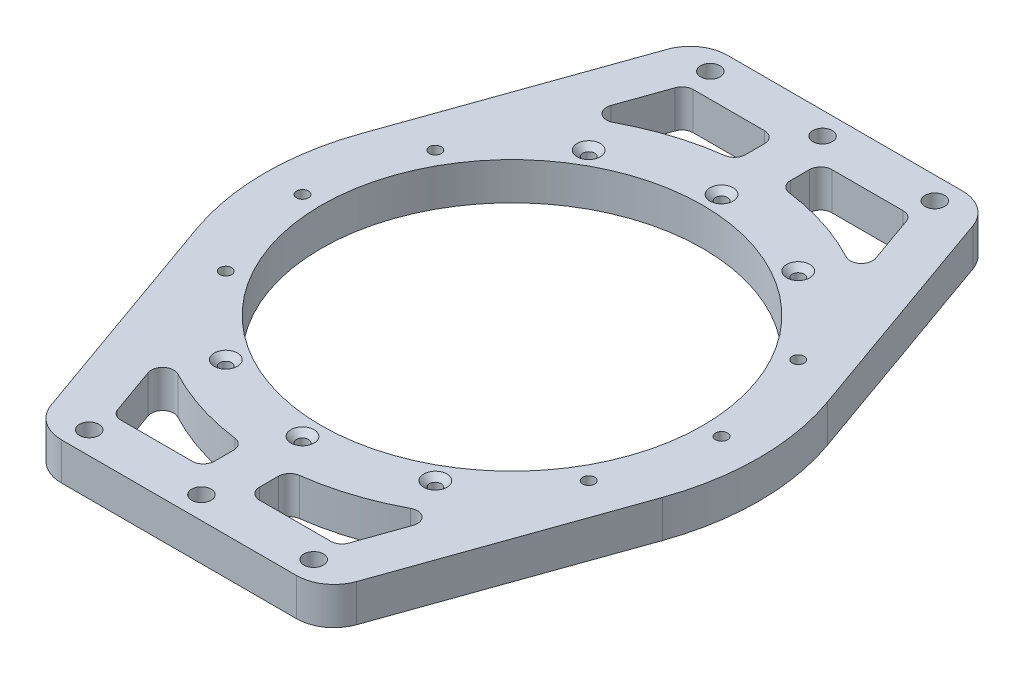
from build123d import *

# Parameters (mm, degrees)
SKETCH_1_W          = 240
SKETCH_1_H          = 180
SKETCH_1_R          = 51
SKETCH_1_R_2        = 1.6
SKETCH_1_R_3        = 2.1
SKETCH_1_R_4        = 1.25
EXTRUDE_1_DEPTH     = 10
CUT_EXTRUDE_1_DEPTH = 11
SKETCH_3_R          = 2.6
SKETCH_3_W          = 240
SKETCH_3_H          = 1
CUT_EXTRUDE_2_DEPTH = 11
CUT_EXTRUDE_3_DEPTH = 11
FILLET_1_R          = 10
CUT_EXTRUDE_4_DEPTH = 11
CHAMFER_1_SIZE      = 1.5


with BuildPart() as part:
    # 草图1 → 凸台-拉伸1 (new body)
    with BuildSketch(Plane(origin=(0, 0, 0), x_dir=(1, 0, 0), z_dir=(0, 1, 0))):
        Rectangle(SKETCH_1_W, SKETCH_1_H)
        Circle(SKETCH_1_R, mode=Mode.SUBTRACT)
        with Locations((0, 56)):
            Circle(SKETCH_1_R_2, mode=Mode.SUBTRACT)
        with Locations((28, 48.497422612)):
            Circle(SKETCH_1_R_2, mode=Mode.SUBTRACT)
        with Locations((48.497422612, 28)):
            Circle(SKETCH_1_R_2, mode=Mode.SUBTRACT)
        with Locations((56, 0)):
            Circle(SKETCH_1_R_2, mode=Mode.SUBTRACT)
        with Locations((48.497422612, -28)):
            Circle(SKETCH_1_R_2, mode=Mode.SUBTRACT)
        with Locations((28, -48.497422612)):
            Circle(SKETCH_1_R_2, mode=Mode.SUBTRACT)
        with Locations((0, -56)):
            Circle(SKETCH_1_R_2, mode=Mode.SUBTRACT)
        with Locations((-28, -48.497422612)):
            Circle(SKETCH_1_R_2, mode=Mode.SUBTRACT)
        with Locations((-48.497422612, -28)):
            Circle(SKETCH_1_R_2, mode=Mode.SUBTRACT)
        with Locations((-56, 0)):
            Circle(SKETCH_1_R_2, mode=Mode.SUBTRACT)
        with Locations((-48.497422612, 28)):
            Circle(SKETCH_1_R_2, mode=Mode.SUBTRACT)
        with Locations((-28, 48.497422612)):
            Circle(SKETCH_1_R_2, mode=Mode.SUBTRACT)
        with Locations((-70, 85)):
            Circle(SKETCH_1_R_3, mode=Mode.SUBTRACT)
        with Locations((-50, 85)):
            Circle(SKETCH_1_R_3, mode=Mode.SUBTRACT)
        with Locations((-70, 65)):
            Circle(SKETCH_1_R_3, mode=Mode.SUBTRACT)
        with Locations((-50, 65)):
            Circle(SKETCH_1_R_3, mode=Mode.SUBTRACT)
        with Locations((50, 85)):
            Circle(SKETCH_1_R_3, mode=Mode.SUBTRACT)
        with Locations((50, 65)):
            Circle(SKETCH_1_R_3, mode=Mode.SUBTRACT)
        with Locations((70, 65)):
            Circle(SKETCH_1_R_3, mode=Mode.SUBTRACT)
        with Locations((70, 85)):
            Circle(SKETCH_1_R_3, mode=Mode.SUBTRACT)
        with Locations((70, -85)):
            Circle(SKETCH_1_R_3, mode=Mode.SUBTRACT)
        with Locations((70, -65)):
            Circle(SKETCH_1_R_3, mode=Mode.SUBTRACT)
        with Locations((50, -65)):
            Circle(SKETCH_1_R_3, mode=Mode.SUBTRACT)
        with Locations((50, -85)):
            Circle(SKETCH_1_R_3, mode=Mode.SUBTRACT)
        with Locations((-50, -65)):
            Circle(SKETCH_1_R_3, mode=Mode.SUBTRACT)
        with Locations((-70, -65)):
            Circle(SKETCH_1_R_3, mode=Mode.SUBTRACT)
        with Locations((-50, -85)):
            Circle(SKETCH_1_R_3, mode=Mode.SUBTRACT)
        with Locations((-70, -85)):
            Circle(SKETCH_1_R_3, mode=Mode.SUBTRACT)
        with Locations((112, 10)):
            Circle(SKETCH_1_R_4, mode=Mode.SUBTRACT)
        with Locations((112, 30)):
            Circle(SKETCH_1_R_4, mode=Mode.SUBTRACT)
        with Locations((112, -30)):
            Circle(SKETCH_1_R_4, mode=Mode.SUBTRACT)
        with Locations((112, -10)):
            Circle(SKETCH_1_R_4, mode=Mode.SUBTRACT)
        with Locations((-112, -30)):
            Circle(SKETCH_1_R_4, mode=Mode.SUBTRACT)
        with Locations((-112, -10)):
            Circle(SKETCH_1_R_4, mode=Mode.SUBTRACT)
        with Locations((-112, 30)):
            Circle(SKETCH_1_R_4, mode=Mode.SUBTRACT)
        with Locations((-112, 10)):
            Circle(SKETCH_1_R_4, mode=Mode.SUBTRACT)
    extrude(amount=EXTRUDE_1_DEPTH)

    # 草图2 → 切除-拉伸1 (cut, through all)
    with BuildSketch(Plane(origin=(0, 10, 0), x_dir=(1, 0, 0), z_dir=(0, 1, 0))):
        Polygon((-120, 57.5), (-110, 47.5), (-110, -47.5), (-120, -57.5), align=None)
        Polygon((110, -47.5), (120, -57.5), (120, 57.5), (110, 47.5), align=None)
    extrude(amount=-CUT_EXTRUDE_1_DEPTH, mode=Mode.SUBTRACT)

    # 草图3 → 切除-拉伸2 (cut, through all)
    with BuildSketch(Plane(origin=(0, 10, 0), x_dir=(1, 0, 0), z_dir=(0, 1, 0))):
        with Locations((-30, 83)):
            Circle(SKETCH_3_R)
        with Locations((0, 83)):
            Circle(SKETCH_3_R)
        with Locations((30, 83)):
            Circle(SKETCH_3_R)
        with Locations((30, -83)):
            Circle(SKETCH_3_R)
        with Locations((0, -83)):
            Circle(SKETCH_3_R)
        with Locations((-30, -83)):
            Circle(SKETCH_3_R)
        with Locations((0, 89.5)):
            Rectangle(SKETCH_3_W, SKETCH_3_H)
        with Locations((0, -89.5)):
            Rectangle(SKETCH_3_W, SKETCH_3_H)
    extrude(amount=-CUT_EXTRUDE_2_DEPTH, mode=Mode.SUBTRACT)

    # 草图4 → 切除-拉伸3 (cut, through all)
    with BuildSketch(Plane(origin=(0, 10, 0), x_dir=(1, 0, 0), z_dir=(0, 1, 0))):
        with BuildLine():
            Line((-38.483126456, 89), (-62.209561842, 22.044736684))
            ThreePointArc((-62.209561842, 22.044736684), (-66, 0), (-62.209561842, -22.044736684))
            Line((-62.209561842, -22.044736684), (-38.483126456, -89))
            Line((-38.483126456, -89), (-120, -89))
            Line((-120, -89), (-120, 89))
            Line((-120, 89), (-38.483126456, 89))
        make_face()
        with BuildLine():
            Line((120, -89), (120, 89))
            Line((120, 89), (38.483126456, 89))
            Line((38.483126456, 89), (62.209561842, 22.044736684))
            ThreePointArc((62.209561842, 22.044736684), (66, 0), (62.209561842, -22.044736684))
            Line((62.209561842, -22.044736684), (38.483126456, -89))
            Line((38.483126456, -89), (120, -89))
        make_face()
    extrude(amount=-CUT_EXTRUDE_3_DEPTH, mode=Mode.SUBTRACT)

    # 圆角1
    fillet_1_edges = [part.edges().sort_by_distance(p)[0] for p in [
        (-38.483126456, 5, -89),
        (-38.483126456, 5, 89),
        (38.483126456, 5, 89),
        (38.483126456, 5, -89),
    ]]
    fillet(fillet_1_edges, radius=FILLET_1_R)

    # 草图7 → 切除-拉伸4 (cut, through all)
    with BuildSketch(Plane(origin=(0, 10, 0), x_dir=(1, 0, 0), z_dir=(0, 1, 0))):
        with BuildLine():
            Line((-9, 76.5), (-28.061793108, 76.5))
            ThreePointArc((-28.061793108, 76.5), (-29.792963167, 75.950112289), (-30.889500465, 74.502033486))
            Line((-30.889500465, 74.502033486), (-35.375296407, 61.843256739))
            ThreePointArc((-35.375296407, 61.843256739), (-34.503237981, 58.566264515), (-31.132476483, 58.195952677))
            ThreePointArc((-31.132476483, 58.195952677), (-20.197656361, 62.833547389), (-8.608695652, 65.436154832))
            ThreePointArc((-8.608695652, 65.436154832), (-6.744571765, 66.432384086), (-6, 68.410525506))
            Line((-6, 68.410525506), (-6, 73.5))
            ThreePointArc((-6, 73.5), (-6.878679656, 75.621320344), (-9, 76.5))
        make_face()
        with BuildLine():
            Line((9, 76.5), (28.061793108, 76.5))
            ThreePointArc((28.061793108, 76.5), (29.792963167, 75.950112289), (30.889500465, 74.502033486))
            Line((30.889500465, 74.502033486), (35.375296407, 61.843256739))
            ThreePointArc((35.375296407, 61.843256739), (34.503237981, 58.566264515), (31.132476483, 58.195952677))
            ThreePointArc((31.132476483, 58.195952677), (20.197656361, 62.833547389), (8.608695652, 65.436154832))
            ThreePointArc((8.608695652, 65.436154832), (6.744571765, 66.432384086), (6, 68.410525506))
            Line((6, 68.410525506), (6, 73.5))
            ThreePointArc((6, 73.5), (6.878679656, 75.621320344), (9, 76.5))
        make_face()
        with BuildLine():
            Line((6, -73.5), (6, -68.410525506))
            ThreePointArc((6, -68.410525506), (6.744571765, -66.432384086), (8.608695652, -65.436154832))
            ThreePointArc((8.608695652, -65.436154832), (20.197656361, -62.833547389), (31.132476483, -58.195952677))
            ThreePointArc((31.132476483, -58.195952677), (34.503237981, -58.566264515), (35.375296407, -61.843256739))
            Line((35.375296407, -61.843256739), (30.889500465, -74.502033486))
            ThreePointArc((30.889500465, -74.502033486), (29.792963167, -75.950112289), (28.061793108, -76.5))
            Line((28.061793108, -76.5), (9, -76.5))
            ThreePointArc((9, -76.5), (6.878679656, -75.621320344), (6, -73.5))
        make_face()
        with BuildLine():
            Line((-9, -76.5), (-28.061793108, -76.5))
            ThreePointArc((-28.061793108, -76.5), (-29.792963167, -75.950112289), (-30.889500465, -74.502033486))
            Line((-30.889500465, -74.502033486), (-35.375296407, -61.843256739))
            ThreePointArc((-35.375296407, -61.843256739), (-34.503237981, -58.566264515), (-31.132476483, -58.195952677))
            ThreePointArc((-31.132476483, -58.195952677), (-20.197656361, -62.833547389), (-8.608695652, -65.436154832))
            ThreePointArc((-8.608695652, -65.436154832), (-6.744571765, -66.432384086), (-6, -68.410525506))
            Line((-6, -68.410525506), (-6, -73.5))
            ThreePointArc((-6, -73.5), (-6.878679656, -75.621320344), (-9, -76.5))
        make_face()
    extrude(amount=-CUT_EXTRUDE_4_DEPTH, mode=Mode.SUBTRACT)

    # 倒角1
    chamfer_1_edges = [part.edges().sort_by_distance(p)[0] for p in [
        (-1.6, 10, -56),
        (26.4, 10, -48.497422612),
        (26.4, 10, 48.497422612),
        (-1.6, 10, 56),
        (-29.6, 10, 48.497422612),
        (-29.6, 10, -48.497422612),
    ]]
    chamfer(chamfer_1_edges, length=CHAMFER_1_SIZE)


solid = part.part
